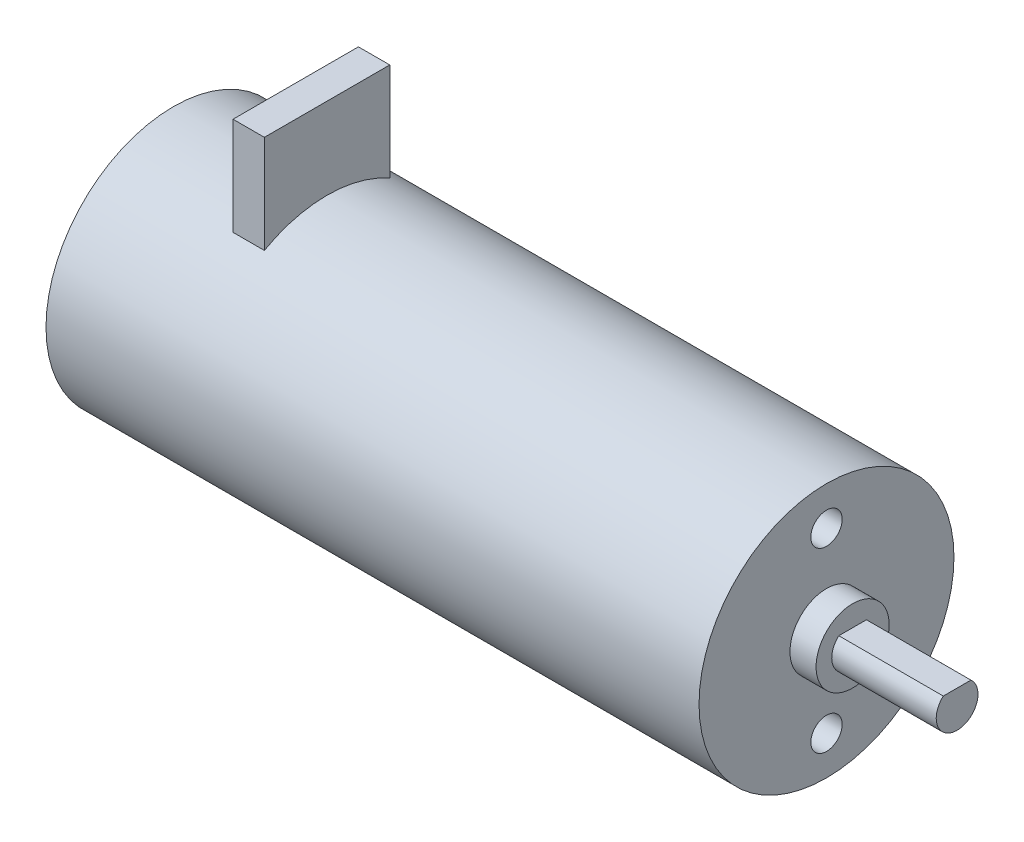
from build123d import *

# Parameters (mm, degrees)
SKETCH1_R           = 12.2
BOSS_EXTRUDE1_DEPTH = 62.5
SKETCH2_R           = 3.5
BOSS_EXTRUDE2_DEPTH = 2.5
BOSS_EXTRUDE3_DEPTH = 10
SKETCH4_R           = 1.5
CUT_EXTRUDE1_DEPTH  = 5
SKETCH5_W           = 3
SKETCH5_H           = 12
BOSS_EXTRUDE4_DEPTH = 20


with BuildPart() as part:
    # Sketch1 → Boss-Extrude1 (new body)
    with BuildSketch(Plane(origin=(0, 0, 0), x_dir=(0, 0, -1), z_dir=(1, 0, 0))):
        Circle(SKETCH1_R)
    extrude(amount=BOSS_EXTRUDE1_DEPTH)

    # Sketch2 → Boss-Extrude2 (add)
    with BuildSketch(Plane(origin=(62.5, 0, 0), x_dir=(0, 0, -1), z_dir=(1, 0, 0))):
        Circle(SKETCH2_R)
    extrude(amount=BOSS_EXTRUDE2_DEPTH)

    # Sketch3 → Boss-Extrude3 (add)
    with BuildSketch(Plane(origin=(65, 0, 0), x_dir=(0, 0, -1), z_dir=(1, 0, 0))):
        with BuildLine():
            Line((-1.322875656, 1.5), (1.322875656, 1.5))
            ThreePointArc((1.322875656, 1.5), (0, -2), (-1.322875656, 1.5))
        make_face()
    extrude(amount=BOSS_EXTRUDE3_DEPTH)

    # Sketch4 → Cut-Extrude1 (cut)
    with BuildSketch(Plane(origin=(62.5, 0, 0), x_dir=(0, 0, -1), z_dir=(1, 0, 0))):
        with Locations((0, 8.5)):
            Circle(SKETCH4_R)
        with Locations((0, -8.5)):
            Circle(SKETCH4_R)
    extrude(amount=-CUT_EXTRUDE1_DEPTH, mode=Mode.SUBTRACT)

    # Sketch5 → Boss-Extrude4 (add)
    with BuildSketch(Plane(origin=(0, 0, 0), x_dir=(1, 0, 0), z_dir=(0, 1, 0))):
        with Locations((13.2, 0)):
            Rectangle(SKETCH5_W, SKETCH5_H)
    extrude(amount=BOSS_EXTRUDE4_DEPTH)


solid = part.part
